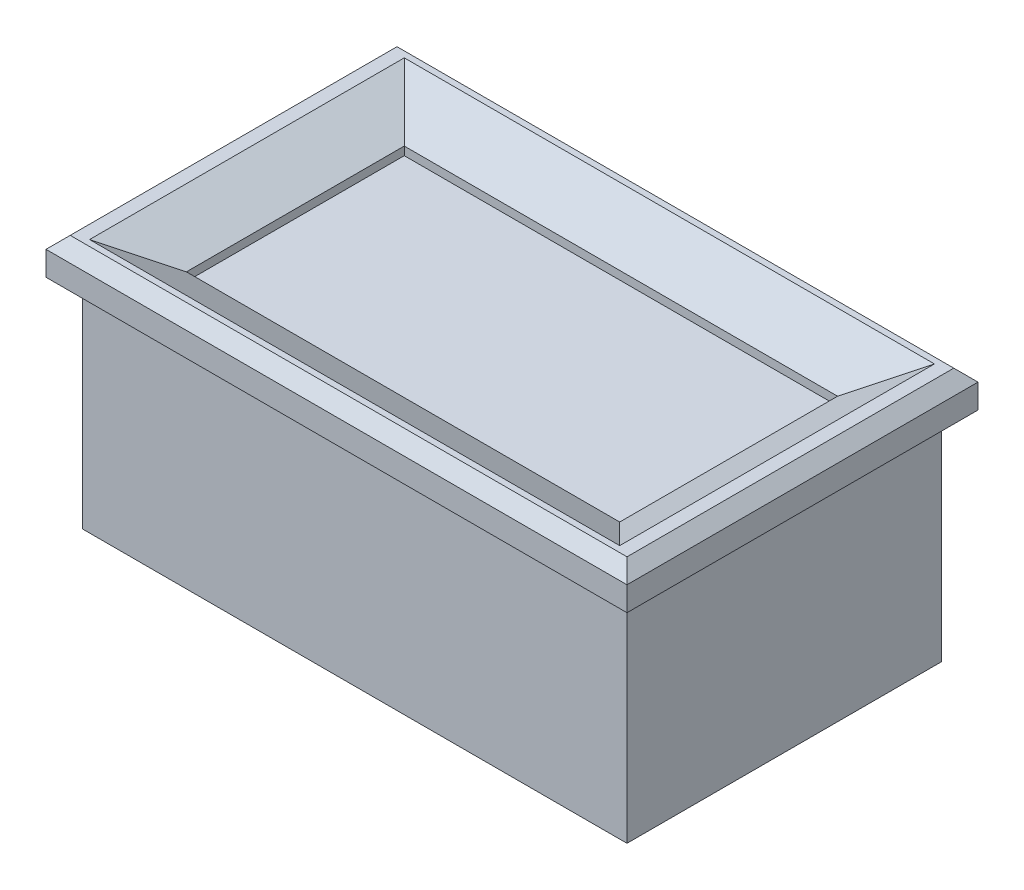
from build123d import *

# Parameters (mm, degrees)
SKETCH1_W           = 45
SKETCH1_H           = 26
BOSS_EXTRUDE1_DEPTH = 18
SKETCH2_W           = 48
SKETCH2_H           = 29
SKETCH2_W_2         = 35.8
SKETCH2_H_2         = 18
BOSS_EXTRUDE2_DEPTH = 3
CHAMFER1_SIZE       = 1
CHAMFER2_SIZE       = 4
CHAMFER2_SIZE2      = 2.309401077


with BuildPart() as part:
    # Sketch1 → Boss-Extrude1 (new body)
    with BuildSketch(Plane(origin=(0, 0, 0), x_dir=(1, 0, 0), z_dir=(0, 1, 0))):
        Rectangle(SKETCH1_W, SKETCH1_H)
    extrude(amount=BOSS_EXTRUDE1_DEPTH)

    # Sketch2 → Boss-Extrude2 (add)
    with BuildSketch(Plane(origin=(0, 18, 0), x_dir=(1, 0, 0), z_dir=(0, 1, 0))):
        Rectangle(SKETCH2_W, SKETCH2_H)
        Rectangle(SKETCH2_W_2, SKETCH2_H_2, mode=Mode.SUBTRACT)
    extrude(amount=BOSS_EXTRUDE2_DEPTH)

    # Chamfer1
    chamfer1_edges = [part.edges().sort_by_distance(p)[0] for p in [
        (24, 21, 0),
        (0, 21, -14.5),
        (-24, 21, 0),
        (0, 21, 14.5),
    ]]
    chamfer(chamfer1_edges, length=CHAMFER1_SIZE)

    # Chamfer2
    chamfer2_edges = [part.edges().sort_by_distance(p)[0] for p in [
        (17.9, 21, 0),
        (0, 21, -9),
        (-17.9, 21, 0),
        (0, 21, 9),
    ]]
    chamfer2_side = [part.faces().sort_by_distance(p)[0] for p in [
        (22.466614586, 21, 0),
    ]]
    chamfer(chamfer2_edges, length=CHAMFER2_SIZE, length2=CHAMFER2_SIZE2, reference=chamfer2_side[0])


solid = part.part
